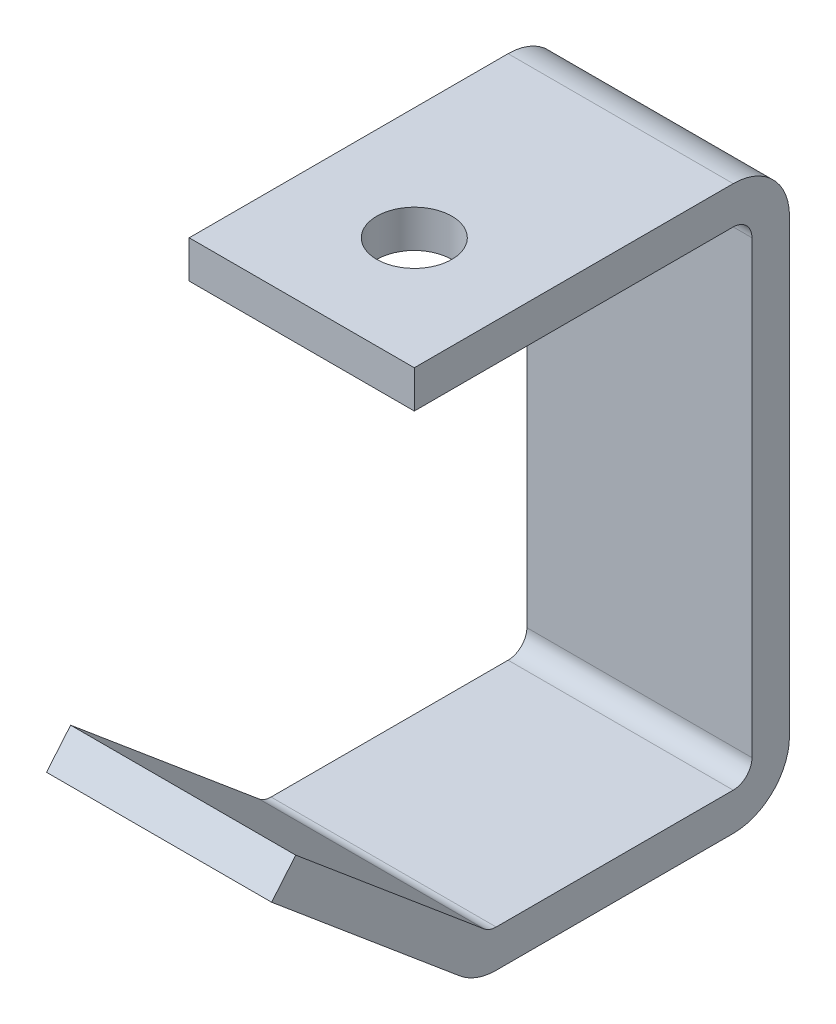
from build123d import *

# Parameters (mm, degrees)
EXTRUDE_THIN1_DEPTH = 19.05
CUT_EXTRUDE1_REACH  = 97.25
SKETCH2_R           = 6.35


with BuildPart() as part:
    # Sketch1 → Extrude-Thin1 (new body, symmetric)
    with BuildSketch(Plane(origin=(0, 0, 0), x_dir=(0, 0, -1), z_dir=(1, 0, 0))):
        with BuildLine():
            Line((-77.216478592, 27.494340102), (-45.335245167, 0.742808893))
            ThreePointArc((-45.335245167, 0.742808893), (-44.380308461, 0.191475929), (-43.294394506, 0))
            Line((-43.294394506, 0), (-3.175, 0))
            ThreePointArc((-3.175, 0), (-0.92993597, 0.92993597), (0, 3.175))
            Line((0, 3.175), (0, 79.375))
            ThreePointArc((0, 79.375), (-0.92993597, 81.62006403), (-3.175, 82.55))
            Line((-3.175, 82.55), (-57.15, 82.55))
            Line((-57.15, 82.55), (-57.15, 88.9))
            Line((-57.15, 88.9), (-3.175, 88.9))
            ThreePointArc((-3.175, 88.9), (3.560192091, 86.110192091), (6.35, 79.375))
            Line((6.35, 79.375), (6.35, 3.175))
            ThreePointArc((6.35, 3.175), (3.560192091, -3.560192091), (-3.175, -6.35))
            Line((-3.175, -6.35), (-43.294394506, -6.35))
            ThreePointArc((-43.294394506, -6.35), (-46.552136371, -5.775572213), (-49.416946488, -4.121573321))
            Line((-49.416946488, -4.121573321), (-81.298179914, 22.629957888))
            Line((-81.298179914, 22.629957888), (-77.216478592, 27.494340102))
        make_face()
    extrude(amount=EXTRUDE_THIN1_DEPTH, both=True)

    # Sketch2 → Cut-Extrude1 (cut, up to next)
    with BuildSketch(Plane(origin=(0, 88.9, 0), x_dir=(1, 0, 0), z_dir=(0, 1, 0)), mode=Mode.PRIVATE) as cut_extrude1_sk1:
        with Locations((0, -38.1)):
            Circle(SKETCH2_R)
    cut_extrude1_tool1 = extrude(cut_extrude1_sk1.sketch, amount=-CUT_EXTRUDE1_REACH, mode=Mode.PRIVATE) & part.part
    add(cut_extrude1_tool1.solids().sort_by_distance((0, 88.9, 38.1))[0], mode=Mode.SUBTRACT)


solid = part.part
